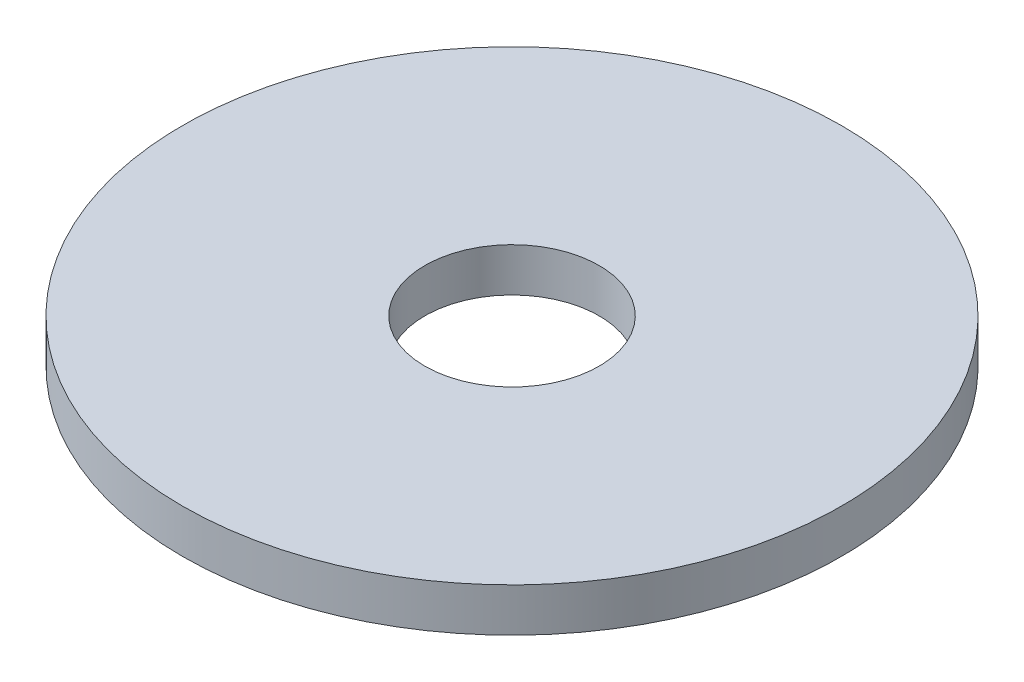
from build123d import *

# Parameters (mm, degrees)
SKETCH1_R           = 6
SKETCH1_R_2         = 1.5875
BOSS_EXTRUDE1_DEPTH = 0.79375


with BuildPart() as part:
    # Sketch1 → Boss-Extrude1 (new body)
    with BuildSketch(Plane(origin=(0, 0, 0), x_dir=(1, 0, 0), z_dir=(0, 1, 0))):
        Circle(SKETCH1_R)
        Circle(SKETCH1_R_2, mode=Mode.SUBTRACT)
    extrude(amount=BOSS_EXTRUDE1_DEPTH)


solid = part.part
